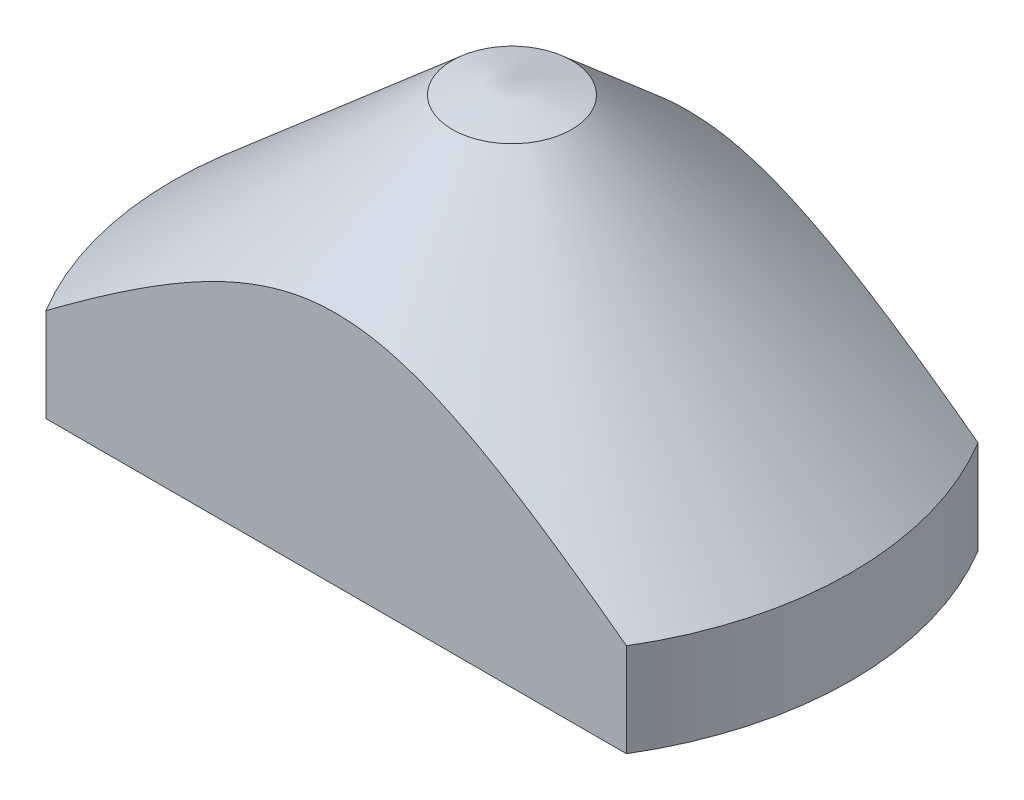
from build123d import *

# Parameters (mm, degrees)
CORTAR_EXTRUIR1_DEPTH = 51


with BuildPart() as part:
    # Croquis1 → Revolución1 (revolve)
    with BuildSketch(Plane.XY):
        Polygon((0, 0), (-48.25, 0), (-48.25, 13.3), (-8.5, 48), (0, 50), align=None)
    revolve(axis=Axis((0, 53.503350084, 0), (0, -1, 0)))

    # Croquis2 → Cortar-Extruir1 (cut, through all)
    with BuildSketch(Plane.XZ):
        with BuildLine():
            ThreePointArc((41.268177813, 25), (0, 48.25), (-41.268177813, 25))
            Line((-41.268177813, 25), (41.268177813, 25))
        make_face()
        with BuildLine():
            Line((41.268177813, -25), (-41.268177813, -25))
            ThreePointArc((-41.268177813, -25), (0, -48.25), (41.268177813, -25))
        make_face()
    extrude(amount=-CORTAR_EXTRUIR1_DEPTH, mode=Mode.SUBTRACT)


solid = part.part
